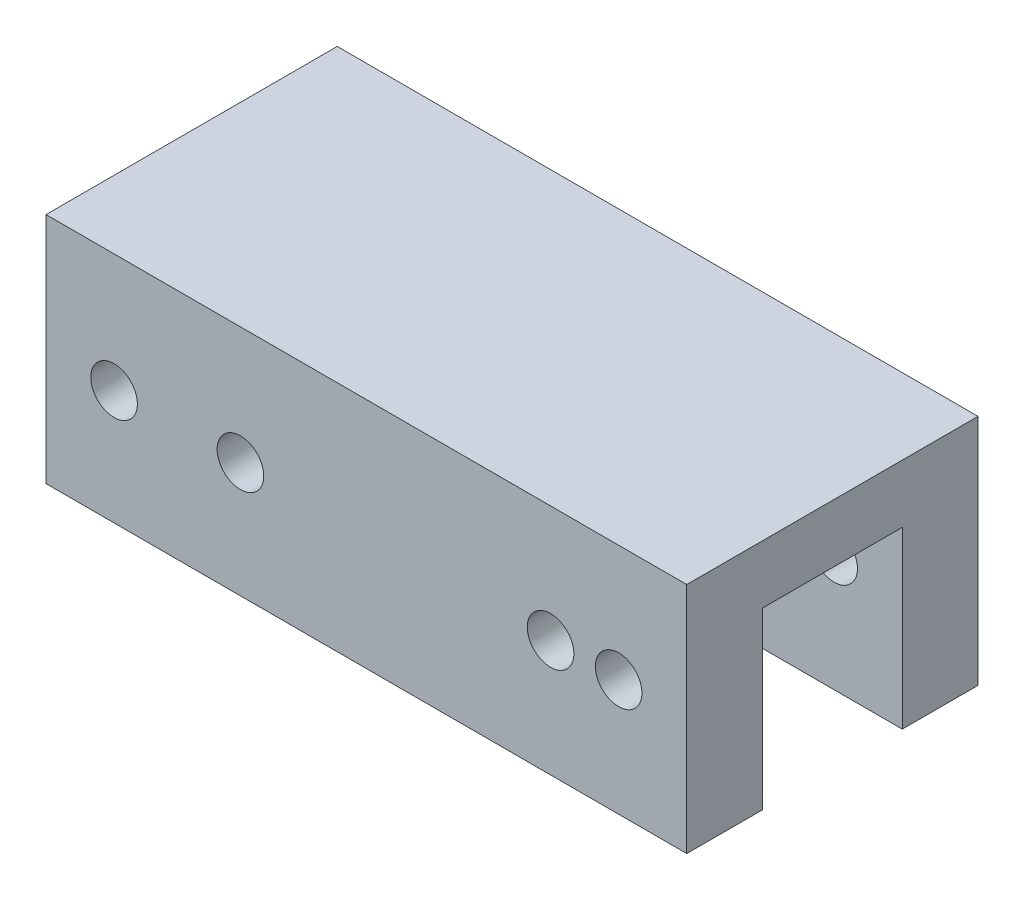
from build123d import *

# Parameters (mm, degrees)
CROQUIS4_W                 = 55
CROQUIS4_H                 = 25
SALIENTE_EXTRUIR3_DEPTH    = 20
CROQUIS5_W                 = 55
CROQUIS5_H                 = 12
CORTAR_EXTRUIR1_DEPTH      = 15
CROQUIS7_R                 = 2
CORTAR_EXTRUIR3_DEPTH      = 1
CORTAR_EXTRUIR3_DEPTH_BACK = 26
CROQUIS14_R                = 2
CORTAR_EXTRUIR6_DEPTH      = 35


with BuildPart() as part:
    # Croquis4 → Saliente-Extruir3 (new body)
    with BuildSketch(Plane(origin=(0, 0, 0), x_dir=(1, 0, 0), z_dir=(0, 1, 0))):
        with Locations((2.725806452, 3.983870968)):
            Rectangle(CROQUIS4_W, CROQUIS4_H)
    extrude(amount=SALIENTE_EXTRUIR3_DEPTH)

    # Croquis5 → Cortar-Extruir1 (cut)
    with BuildSketch(Plane(origin=(0, 0, 0), x_dir=(-1, 0, 0), z_dir=(0, -1, 0))):
        with Locations((-2.725806452, 3.983870968)):
            Rectangle(CROQUIS5_W, CROQUIS5_H)
    extrude(amount=-CORTAR_EXTRUIR1_DEPTH, mode=Mode.SUBTRACT)

    # Croquis7 → Cortar-Extruir3 (cut, two sides)
    with BuildSketch(Plane(origin=(0, 0, -16.483870968), x_dir=(-1, 0, 0), z_dir=(0, 0, -1))) as cortar_extruir3_sk:
        with Locations((-24.380806452, 10)):
            Circle(CROQUIS7_R)
        with Locations((-18.535806452, 10)):
            Circle(CROQUIS7_R)
    extrude(amount=CORTAR_EXTRUIR3_DEPTH, mode=Mode.SUBTRACT)
    extrude(cortar_extruir3_sk.sketch, amount=-CORTAR_EXTRUIR3_DEPTH_BACK, mode=Mode.SUBTRACT)

    # Croquis14 → Cortar-Extruir6 (cut)
    with BuildSketch(Plane(origin=(0, 0, -16.483870968), x_dir=(-1, 0, 0), z_dir=(0, 0, -1))):
        with Locations((8.084193548, 9.903617559)):
            Circle(CROQUIS14_R)
        with Locations((18.929193548, 9.838818962)):
            Circle(CROQUIS14_R)
    extrude(amount=-CORTAR_EXTRUIR6_DEPTH, mode=Mode.SUBTRACT)


solid = part.part
